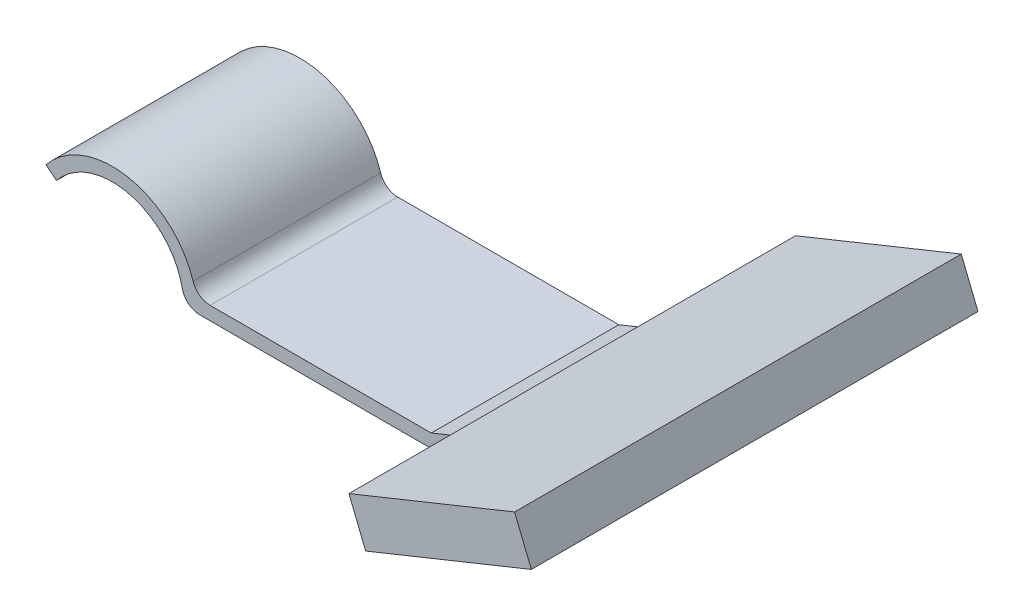
from build123d import *

# Parameters (mm, degrees)
EXTRUDE_THIN1_DEPTH = 10.5
FILLET1_R           = 2
FILLET2_R           = 2
SKETCH3_W           = 50
SKETCH3_H           = 5
BOSS_EXTRUDE1_DEPTH = 20


with BuildPart() as part:
    # Sketch1 → Extrude-Thin1 (new body, symmetric)
    with BuildSketch(Plane.XY):
        with BuildLine():
            ThreePointArc((-14.244997998, 5), (-5.350470229, 7.548509256), (0, 0))
            Line((0, 0), (28, 0))
            Line((28, 0), (52.755002002, 10))
            Line((52.755002002, 10), (52.193172773, 11.390808368))
            Line((52.193172773, 11.390808368), (27.708474677, 1.5))
            Line((27.708474677, 1.5), (1.38083152, 1.5))
            ThreePointArc((1.38083152, 1.5), (-5.573468314, 9.184875828), (-15.415935123, 5.9375))
            Line((-15.415935123, 5.9375), (-14.244997998, 5))
        make_face()
    extrude(amount=EXTRUDE_THIN1_DEPTH, both=True)

    # Fillet1
    fillet1_edges = [part.edges().sort_by_distance(p)[0] for p in [
        (0, 0, 0),
    ]]
    fillet(fillet1_edges, radius=FILLET1_R)

    # Fillet2
    fillet2_edges = [part.edges().sort_by_distance(p)[0] for p in [
        (1.38083152, 1.5, 0),
    ]]
    fillet(fillet2_edges, radius=FILLET2_R)

    # Sketch3 → Boss-Extrude1 (add)
    with BuildSketch(Plane(origin=(48.826887199, 19.72404898, 0), x_dir=(0, 0, -1), z_dir=(0.927205579, 0.374552819, 0))):
        with Locations((0, -9.737478938)):
            Rectangle(SKETCH3_W, SKETCH3_H)
    extrude(amount=-BOSS_EXTRUDE1_DEPTH)


solid = part.part
